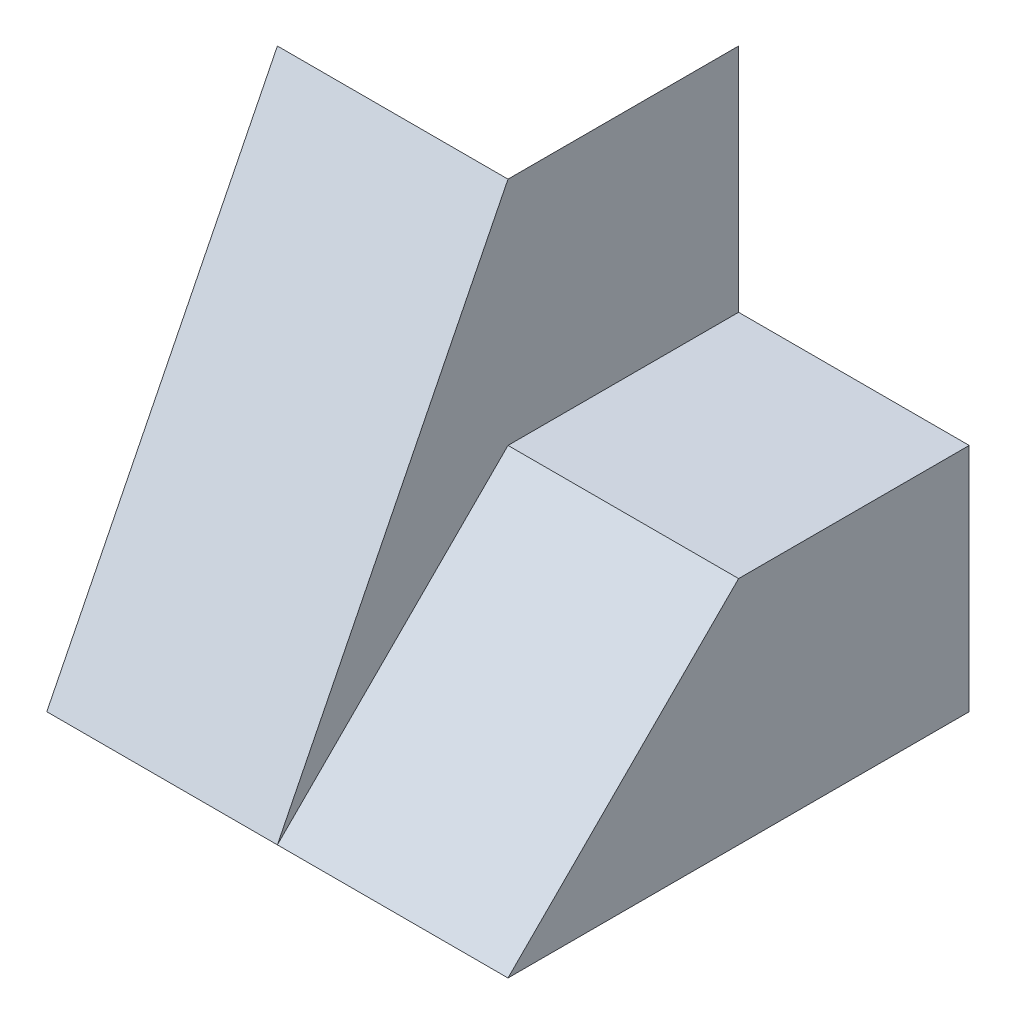
from build123d import *

# Parameters (mm, degrees)
SKETCH1_W           = 40
SKETCH1_H           = 40
BOSS_EXTRUDE1_DEPTH = 40
SKETCH2_W           = 20
SKETCH2_H           = 20
CUT_EXTRUDE1_DEPTH  = 40
CUT_EXTRUDE2_DEPTH  = 20
CUT_EXTRUDE4_DEPTH  = 20
CUT_EXTRUDE5_DEPTH  = 20


with BuildPart() as part:
    # Sketch1 → Boss-Extrude1 (new body)
    with BuildSketch(Plane.XY):
        with Locations((20, 20)):
            Rectangle(SKETCH1_W, SKETCH1_H)
    extrude(amount=BOSS_EXTRUDE1_DEPTH)

    # Sketch2 → Cut-Extrude1 (cut)
    with BuildSketch(Plane.XY.offset(40)):
        with Locations((30, 30)):
            Rectangle(SKETCH2_W, SKETCH2_H)
    extrude(amount=-CUT_EXTRUDE1_DEPTH, mode=Mode.SUBTRACT)

    # Sketch3 → Cut-Extrude2 (cut)
    with BuildSketch(Plane(origin=(40, 0, 0), x_dir=(0, 0, -1), z_dir=(1, 0, 0))):
        Polygon((-40, 0), (-20, 20), (-40, 20), align=None)
    extrude(amount=-CUT_EXTRUDE2_DEPTH, mode=Mode.SUBTRACT)

    # Sketch5 → Cut-Extrude4 (cut)
    with BuildSketch(Plane(origin=(0, 0, 0), x_dir=(-1, 0, 0), z_dir=(0, 0, -1))):
        Polygon((-20, 40), (0, 20), (0, 40), align=None)
    extrude(amount=-CUT_EXTRUDE4_DEPTH, mode=Mode.SUBTRACT)

    # Sketch6 → Cut-Extrude5 (cut)
    with BuildSketch(Plane.ZY):
        Polygon((20, 40), (40, 0), (40, 40), align=None)
    extrude(amount=-CUT_EXTRUDE5_DEPTH, mode=Mode.SUBTRACT)


solid = part.part
